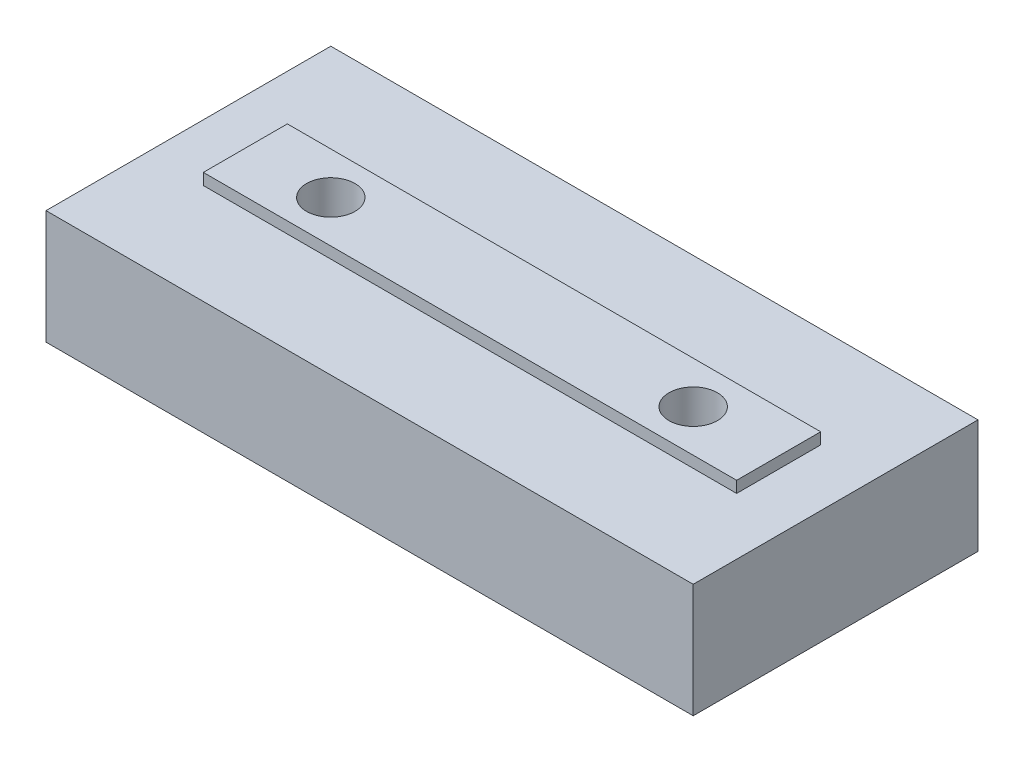
from build123d import *

# Parameters (mm, degrees)
SKETCH1_W            = 45.45
SKETCH1_H            = 20
BOSS_EXTRUDE1_DEPTH  = 8
SKETCH2_W            = 37.45
SKETCH2_H            = 5.9
BOSS_EXTRUDE2_DEPTH  = 0.8
M3_CLEARANCE_HOLE1_D = 3.4


with BuildPart() as part:
    # Sketch1 → Boss-Extrude1 (new body)
    with BuildSketch(Plane(origin=(0, 0, 0), x_dir=(1, 0, 0), z_dir=(0, 1, 0))):
        with Locations((7.654765617, -1.92370193)):
            Rectangle(SKETCH1_W, SKETCH1_H)
    extrude(amount=BOSS_EXTRUDE1_DEPTH)

    # Sketch2 → Boss-Extrude2 (add)
    with BuildSketch(Plane(origin=(0, 8, 0), x_dir=(1, 0, 0), z_dir=(0, 1, 0))):
        with Locations((7.654765617, -1.92370193)):
            Rectangle(SKETCH2_W, SKETCH2_H)
    extrude(amount=BOSS_EXTRUDE2_DEPTH)

    # M3 Clearance Hole1 (through all)
    with Locations(Plane(origin=(0, 0, 0), x_dir=(-1, 0, 0), z_dir=(0, -1, 0))):
        with Locations((-20.379765617, -1.92370193), (5.070234383, -1.92370193)):
            Hole(M3_CLEARANCE_HOLE1_D / 2)


solid = part.part
